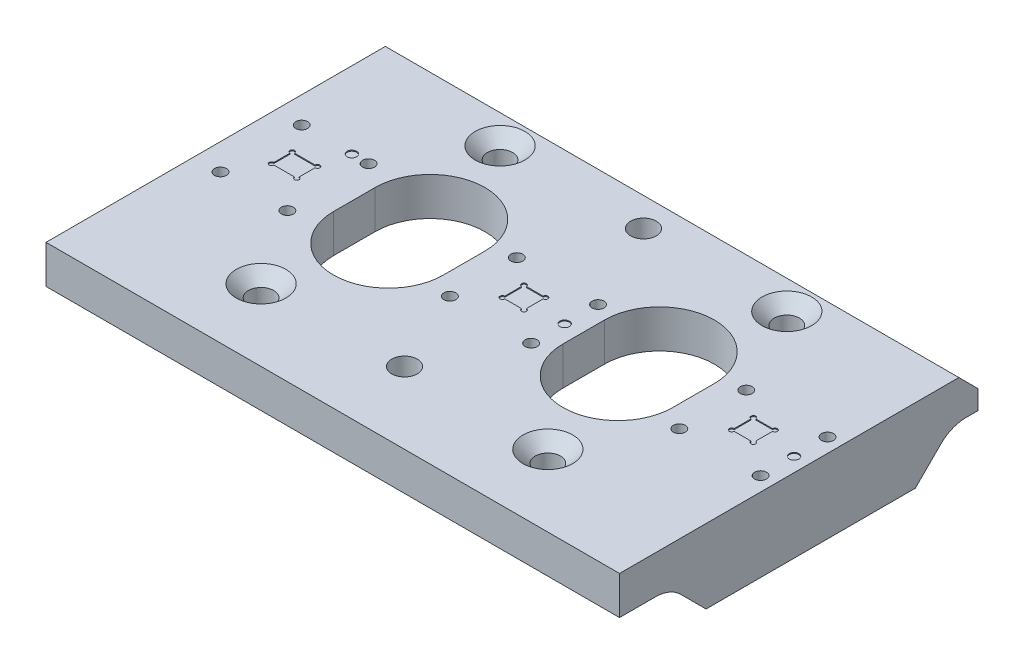
from build123d import *

# Parameters (mm, degrees)
SKETCH_5_W                  = 120
SKETCH_5_H                  = 75
EXTRUDE_2_DEPTH             = 8
SKETCH2_R                   = 1
CUT_EXTRUDE2_DEPTH          = 0.2
SKETCH3_R                   = 1
CUT_EXTRUDE3_DEPTH          = 0.2
M3X0_5_TAPPED_HOLE1_D       = 2.5
M3X0_5_TAPPED_HOLE1_DEPTH   = 5.5
M3X0_5_TAPPED_HOLE1_TIP     = 0.751075774
HOLE_WIZARD_M51_D           = 5.3
HOLE_WIZARD_M51_CSINK_D     = 10.4
HOLE_WIZARD_M51_CSINK_ANGLE = 90
SKETCH6_R                   = 2.6
CUT_EXTRUDE4_DEPTH          = 9
CUT_EXTRUDE4_TAPER          = -0.573055556
CUT_EXTRUDE_1_DEPTH         = 10
EXTRUDE_3_DEPTH             = 120
SKETCH_9_W                  = 92
SKETCH_9_H                  = 19.20799114
CUT_EXTRUDE_3_DEPTH         = 76
CHAMFER_1_SIZE              = 4


with BuildPart() as part:
    # Эскиз5 → Бобышка-Вытянуть2 (new body)
    with BuildSketch(Plane(origin=(0, 0, 0), x_dir=(1, 0, 0), z_dir=(0, 1, 0))):
        with Locations((60, -2.5)):
            Rectangle(SKETCH_5_W, SKETCH_5_H)
    extrude(amount=-EXTRUDE_2_DEPTH)

    # Sketch2 → Cut-Extrude2 (cut)
    with BuildSketch(Plane(origin=(0, 0, 0), x_dir=(1, 0, 0), z_dir=(0, 1, 0))):
        with Locations((117.027, -0.519)):
            Circle(SKETCH2_R)
        with Locations((69.027, -0.519)):
            Circle(SKETCH2_R)
        with BuildLine():
            Line((106.24, -2.26), (109.76, -2.26))
            ThreePointArc((109.76, -2.26), (110.613553391, -2.613553391), (110.26, -1.76))
            Line((110.26, -1.76), (110.26, 1.76))
            ThreePointArc((110.26, 1.76), (110.613553391, 2.613553391), (109.76, 2.26))
            Line((109.76, 2.26), (106.24, 2.26))
            ThreePointArc((106.24, 2.26), (105.386446609, 2.613553391), (105.74, 1.76))
            Line((105.74, 1.76), (105.74, -1.76))
            ThreePointArc((105.74, -1.76), (105.386446609, -2.613553391), (106.24, -2.26))
        make_face()
        with BuildLine():
            Line((58.24, -2.26), (61.76, -2.26))
            ThreePointArc((61.76, -2.26), (62.613553391, -2.613553391), (62.26, -1.76))
            Line((62.26, -1.76), (62.26, 1.76))
            ThreePointArc((62.26, 1.76), (62.613553391, 2.613553391), (61.76, 2.26))
            Line((61.76, 2.26), (58.24, 2.26))
            ThreePointArc((58.24, 2.26), (57.386446609, 2.613553391), (57.74, 1.76))
            Line((57.74, 1.76), (57.74, -1.76))
            ThreePointArc((57.74, -1.76), (57.386446609, -2.613553391), (58.24, -2.26))
        make_face()
    extrude(amount=-CUT_EXTRUDE2_DEPTH, mode=Mode.SUBTRACT)

    # Sketch3 → Cut-Extrude3 (cut)
    with BuildSketch(Plane(origin=(0, 0, 0), x_dir=(1, 0, 0), z_dir=(0, 1, 0))):
        with Locations((16, 8)):
            Circle(SKETCH3_R)
        with BuildLine():
            Line((9.86, -2.16), (14.14, -2.16))
            ThreePointArc((14.14, -2.16), (14.993553391, -2.513553391), (14.64, -1.66))
            Line((14.64, -1.66), (14.64, 1.66))
            ThreePointArc((14.64, 1.66), (14.993553391, 2.513553391), (14.14, 2.16))
            Line((14.14, 2.16), (9.86, 2.16))
            ThreePointArc((9.86, 2.16), (9.006446609, 2.513553391), (9.36, 1.66))
            Line((9.36, 1.66), (9.36, -1.66))
            ThreePointArc((9.36, -1.66), (9.006446609, -2.513553391), (9.86, -2.16))
        make_face()
    extrude(amount=-CUT_EXTRUDE3_DEPTH, mode=Mode.SUBTRACT)

    # M3x0.5 Tapped Hole1
    with Locations(Plane(origin=(0, 0, 0), x_dir=(1, 0, 0), z_dir=(0, 1, 0))):
        with Locations((5.5, 8), (19.5, 8), (19.5, -9), (5.5, -9), (52.027, 6.481), (69.027, 6.481), (69.027, -7.519), (52.027, -7.519), (100.027, 6.481), (117.027, 6.481), (117.027, -7.519), (100.027, -7.519)):
            Hole(M3X0_5_TAPPED_HOLE1_D / 2, depth=M3X0_5_TAPPED_HOLE1_DEPTH)
            with Locations((0, 0, -(M3X0_5_TAPPED_HOLE1_DEPTH + M3X0_5_TAPPED_HOLE1_TIP / 2))):  # 118° drill point
                Cone(0, M3X0_5_TAPPED_HOLE1_D / 2, M3X0_5_TAPPED_HOLE1_TIP, mode=Mode.SUBTRACT)

    # Зенковка для  винта с плоской головкой M51 (through all)
    with Locations(Plane(origin=(0, 0, 0), x_dir=(1, 0, 0), z_dir=(0, 1, 0))):
        with Locations((30, 25), (90, 25), (90, -25), (30, -25)):
            CounterSinkHole(HOLE_WIZARD_M51_D / 2, HOLE_WIZARD_M51_CSINK_D / 2, counter_sink_angle=HOLE_WIZARD_M51_CSINK_ANGLE)

    # Sketch6 → Cut-Extrude4 (cut, through all)
    with BuildSketch(Plane.XZ.offset(8)):
        with Locations((60, -25)):
            Circle(SKETCH6_R)
        with Locations((60, 25)):
            Circle(SKETCH6_R)
    extrude(amount=-CUT_EXTRUDE4_DEPTH, taper=CUT_EXTRUDE4_TAPER, mode=Mode.SUBTRACT)

    # Эскиз7 → Вырез-Вытянуть1 (cut)
    with BuildSketch(Plane(origin=(0, 0, 0), x_dir=(1, 0, 0), z_dir=(0, 1, 0))):
        with BuildLine():
            Line((47.5, 4.354177178), (47.5, -4.354177178))
            ThreePointArc((47.5, -4.354177178), (36, -15.854177178), (24.5, -4.354177178))
            Line((24.5, -4.354177178), (24.5, 4.354177178))
            ThreePointArc((24.5, 4.354177178), (36, 15.854177178), (47.5, 4.354177178))
        make_face()
        with BuildLine():
            Line((95.5, 4.354177178), (95.5, -4.354177178))
            ThreePointArc((95.5, -4.354177178), (84, -15.854177178), (72.5, -4.354177178))
            Line((72.5, -4.354177178), (72.5, 4.354177178))
            ThreePointArc((72.5, 4.354177178), (84, 15.854177178), (95.5, 4.354177178))
        make_face()
    extrude(amount=-CUT_EXTRUDE_1_DEPTH, mode=Mode.SUBTRACT)

    # Эскиз8 → Бобышка-Вытянуть3 (add, through all)
    with BuildSketch(Plane(origin=(120, 0, 0), x_dir=(0, 0, -1), z_dir=(1, 0, 0))):
        with BuildLine():
            Line((-21.893398282, -15.5), (21.893398282, -15.5))
            Line((21.893398282, -15.5), (27.196699141, -10.196699141))
            ThreePointArc((27.196699141, -10.196699141), (29.629874257, -8.570903506), (32.5, -8))
            Line((32.5, -8), (-32.5, -8))
            ThreePointArc((-32.5, -8), (-29.629874257, -8.570903506), (-27.196699141, -10.196699141))
            Line((-27.196699141, -10.196699141), (-21.893398282, -15.5))
        make_face()
    extrude(amount=-EXTRUDE_3_DEPTH)

    # Эскиз9 → Вырез-Вытянуть3 (cut, through all)
    with BuildSketch(Plane.XY.offset(40)):
        with Locations((60, -17.60399557)):
            Rectangle(SKETCH_9_W, SKETCH_9_H)
    extrude(amount=-CUT_EXTRUDE_3_DEPTH, mode=Mode.SUBTRACT)

    # Фаска1
    chamfer_1_edges = [part.edges().sort_by_distance(p)[0] for p in [
        (60, 0, -35),
    ]]
    chamfer(chamfer_1_edges, length=CHAMFER_1_SIZE)


solid = part.part
